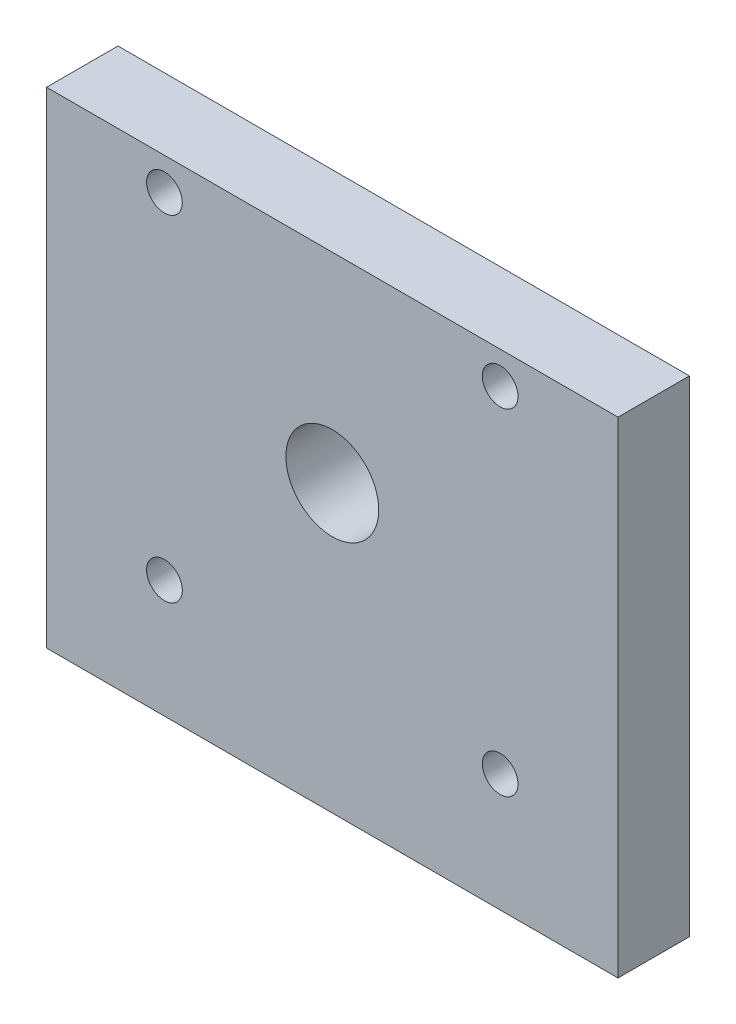
from build123d import *

# Parameters (mm, degrees)
SKETCH_1_W      = 80
SKETCH_1_H      = 68
SKETCH_1_R      = 6.5
SKETCH_1_R_2    = 2.5
EXTRUDE_1_DEPTH = 10


with BuildPart() as part:
    # 草图1 → 凸台-拉伸1 (new body)
    with BuildSketch(Plane.XY):
        with Locations((3.948018328, -9.068493151)):
            Rectangle(SKETCH_1_W, SKETCH_1_H)
        with Locations((3.948018328, -3.068493151)):
            Circle(SKETCH_1_R, mode=Mode.SUBTRACT)
        with Locations((-19.551981672, 20.431506849)):
            Circle(SKETCH_1_R_2, mode=Mode.SUBTRACT)
        with Locations((27.448018328, 20.431506849)):
            Circle(SKETCH_1_R_2, mode=Mode.SUBTRACT)
        with Locations((27.448018328, -26.568493151)):
            Circle(SKETCH_1_R_2, mode=Mode.SUBTRACT)
        with Locations((-19.551981672, -26.568493151)):
            Circle(SKETCH_1_R_2, mode=Mode.SUBTRACT)
    extrude(amount=EXTRUDE_1_DEPTH)


solid = part.part
